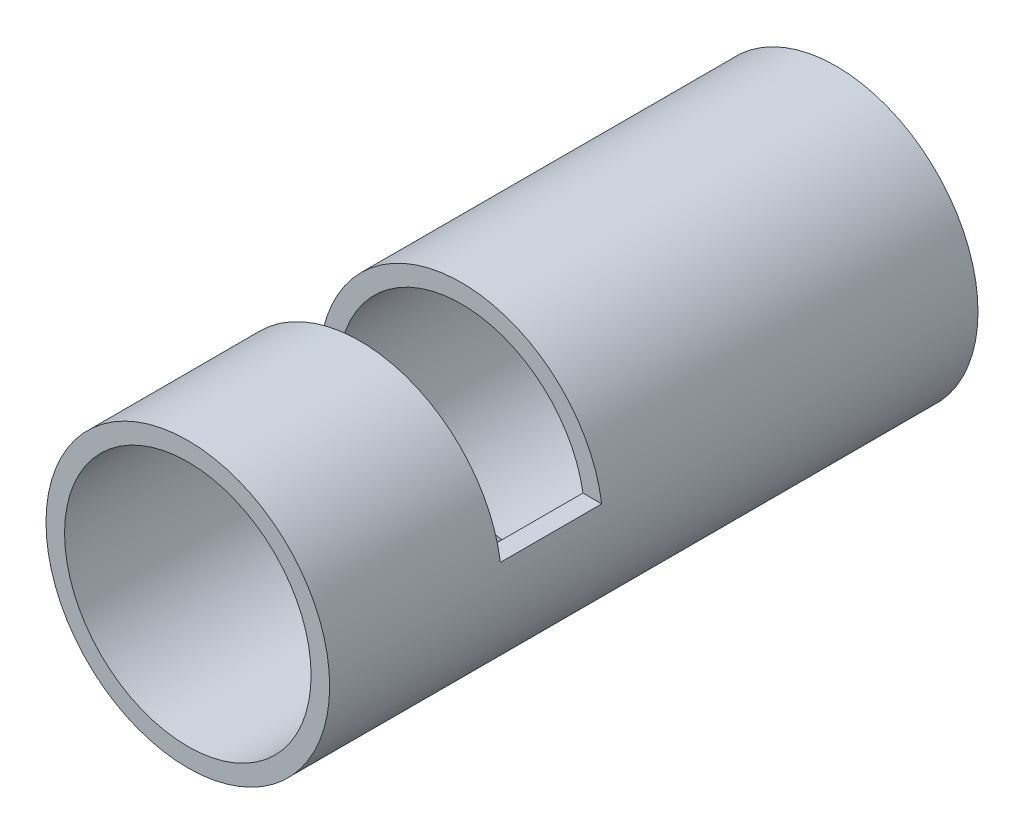
from build123d import *

# Parameters (mm, degrees)
SKETCH1_R              = 44.45
SKETCH1_R_2            = 38.6334
BASE_DEPTH             = 203.2
SKETCH2_W              = 31.75
SKETCH2_H              = 38.1
SANDING_CUT_DEPTH      = 45.45
SANDING_CUT_DEPTH_BACK = 45.45
SKETCH3_W              = 38.1
SKETCH3_H              = 12.7
SERVO_CUT_DEPTH        = 45.45
SERVO_CUT_DEPTH_BACK   = 45.45


with BuildPart() as part:
    # Sketch1 → base (new body)
    with BuildSketch(Plane.XY):
        Circle(SKETCH1_R)
        Circle(SKETCH1_R_2, mode=Mode.SUBTRACT)
    extrude(amount=BASE_DEPTH)

    # Sketch2 → sanding cut (cut, two sides)
    with BuildSketch(Plane(origin=(0, 0, 0), x_dir=(0, 0, -1), z_dir=(1, 0, 0))) as sanding_cut_sk:
        with Locations((-133.35, 25.4)):
            Rectangle(SKETCH2_W, SKETCH2_H)
    extrude(amount=SANDING_CUT_DEPTH, mode=Mode.SUBTRACT)
    extrude(sanding_cut_sk.sketch, amount=-SANDING_CUT_DEPTH_BACK, mode=Mode.SUBTRACT)

    # Sketch3 → servo cut (cut, two sides)
    with BuildSketch(Plane(origin=(0, 0, 0), x_dir=(0, 0, -1), z_dir=(1, 0, 0))) as servo_cut_sk:
        with Locations((-117.475, -38.1)):
            Rectangle(SKETCH3_W, SKETCH3_H)
    extrude(amount=SERVO_CUT_DEPTH, mode=Mode.SUBTRACT)
    extrude(servo_cut_sk.sketch, amount=-SERVO_CUT_DEPTH_BACK, mode=Mode.SUBTRACT)


solid = part.part
